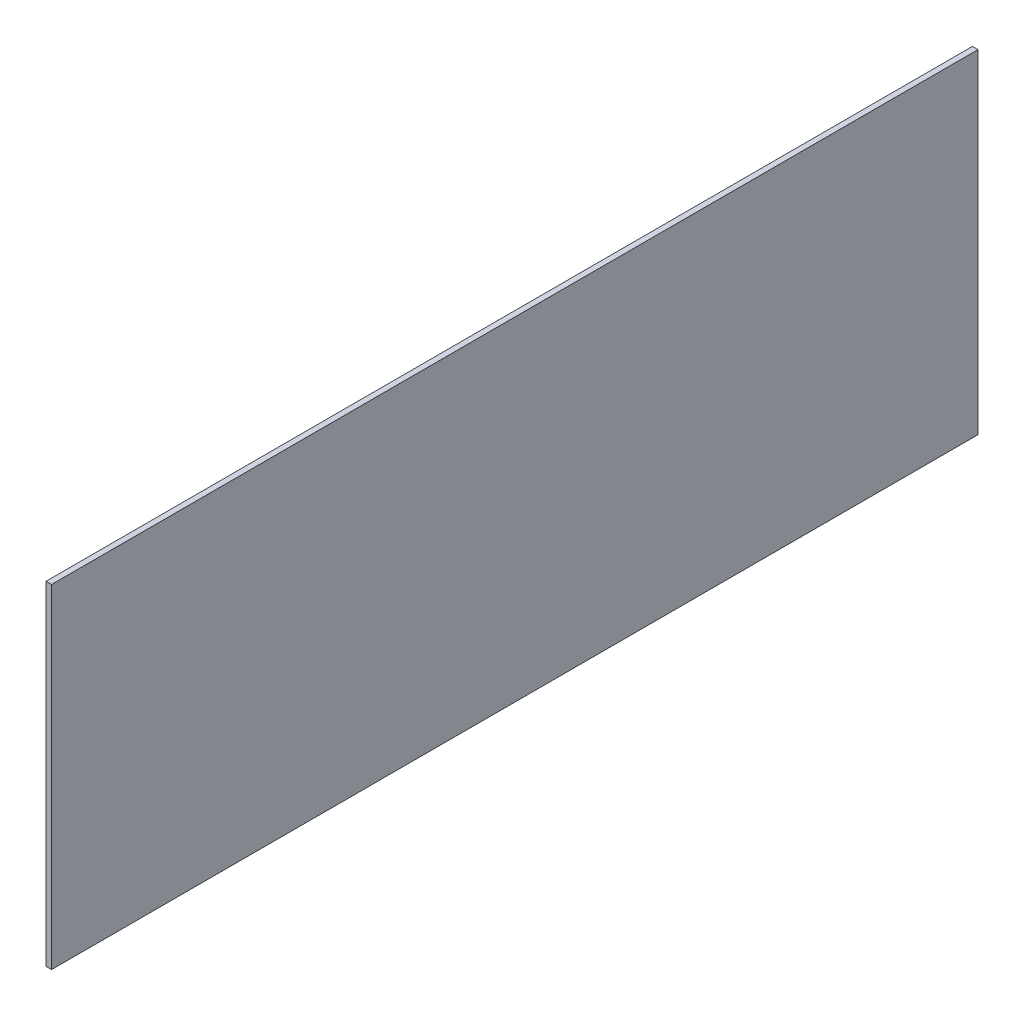
from build123d import *

# Parameters (mm, degrees)
SKETCH_1_W      = 5000
SKETCH_1_H      = 1800
EXTRUDE_1_DEPTH = 30


with BuildPart() as part:
    # Эскиз1 → Бобышка-Вытянуть1 (new body)
    with BuildSketch(Plane(origin=(0, 0, 0), x_dir=(0, 0, -1), z_dir=(1, 0, 0))):
        with Locations((2500, 900)):
            Rectangle(SKETCH_1_W, SKETCH_1_H)
    extrude(amount=EXTRUDE_1_DEPTH)


solid = part.part
